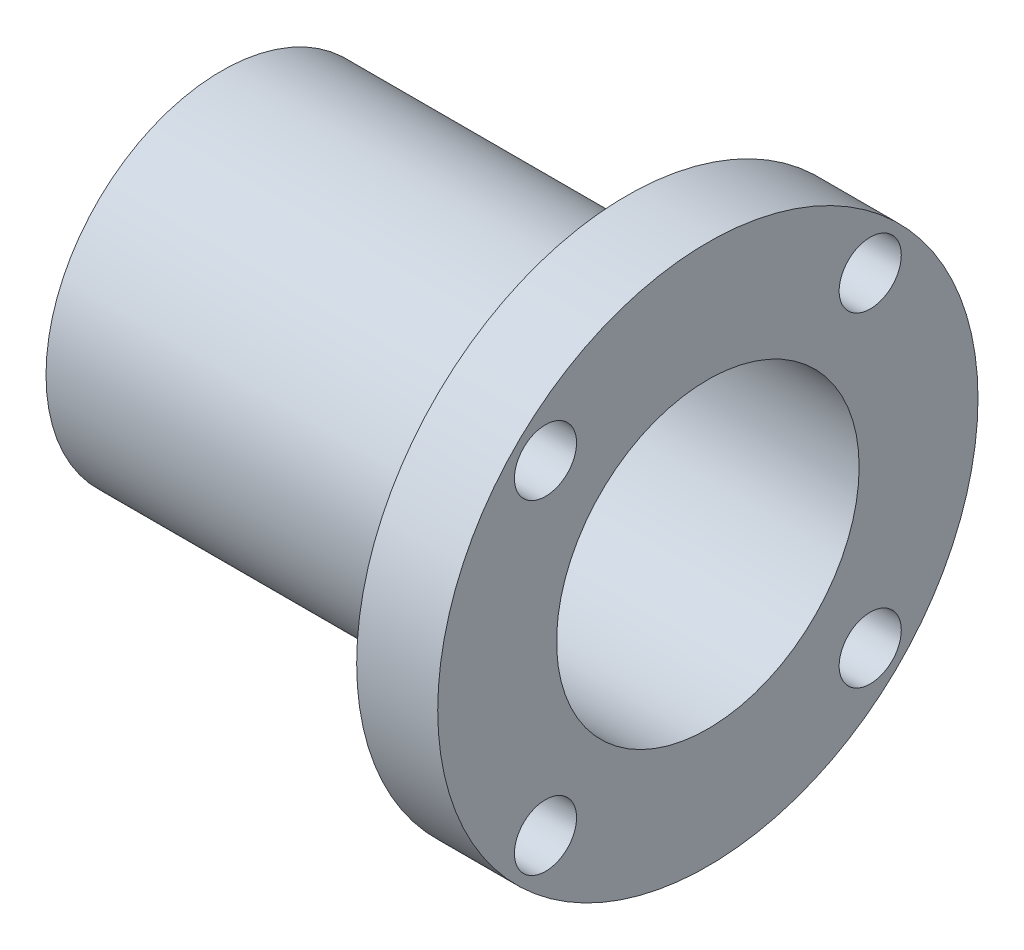
from build123d import *

# Parameters (mm, degrees)
SKETCH2_R           = 10
BOSS_EXTRUDE1_DEPTH = 3
SKETCH3_R           = 6.5
SKETCH3_R_2         = 5.6
BOSS_EXTRUDE2_DEPTH = 15
BOSS_EXTRUDE3_START = -15
SKETCH4_R           = 6.5
SKETCH4_R_2         = 2.095
BOSS_EXTRUDE3_DEPTH = 3
SKETCH5_R           = 5.6
CUT_EXTRUDE1_DEPTH  = 3
SKETCH6_R           = 1.15
CUT_EXTRUDE2_DEPTH  = 4


with BuildPart() as part:
    # Sketch2 → Boss-Extrude1 (new body)
    with BuildSketch(Plane(origin=(0, 0, 0), x_dir=(0, 0, -1), z_dir=(1, 0, 0))):
        Circle(SKETCH2_R)
    extrude(amount=BOSS_EXTRUDE1_DEPTH)

    # Sketch3 → Boss-Extrude2 (add)
    with BuildSketch(Plane(origin=(0, 0, 0), x_dir=(0, 0, -1), z_dir=(1, 0, 0))):
        Circle(SKETCH3_R)
        Circle(SKETCH3_R_2, mode=Mode.SUBTRACT)
    extrude(amount=-BOSS_EXTRUDE2_DEPTH)

    # Sketch4 → Boss-Extrude3 (add)
    with BuildSketch(Plane(origin=(0, 0, 0), x_dir=(0, 0, -1), z_dir=(1, 0, 0)).offset(BOSS_EXTRUDE3_START)):
        Circle(SKETCH4_R)
        Circle(SKETCH4_R_2, mode=Mode.SUBTRACT)
    extrude(amount=BOSS_EXTRUDE3_DEPTH)

    # Sketch5 → Cut-Extrude1 (cut)
    with BuildSketch(Plane(origin=(0, 0, 0), x_dir=(0, 0, -1), z_dir=(1, 0, 0))):
        Circle(SKETCH5_R)
    extrude(amount=CUT_EXTRUDE1_DEPTH, mode=Mode.SUBTRACT)

    # Sketch6 → Cut-Extrude2 (cut, through all)
    with BuildSketch(Plane(origin=(0, 0, 0), x_dir=(0, 0, -1), z_dir=(1, 0, 0))):
        with Locations((6.01040764, 6.01040764)):
            Circle(SKETCH6_R)
        with Locations((6.01040764, -6.01040764)):
            Circle(SKETCH6_R)
        with Locations((-6.01040764, -6.01040764)):
            Circle(SKETCH6_R)
        with Locations((-6.01040764, 6.01040764)):
            Circle(SKETCH6_R)
    extrude(amount=CUT_EXTRUDE2_DEPTH, mode=Mode.SUBTRACT)


solid = part.part
